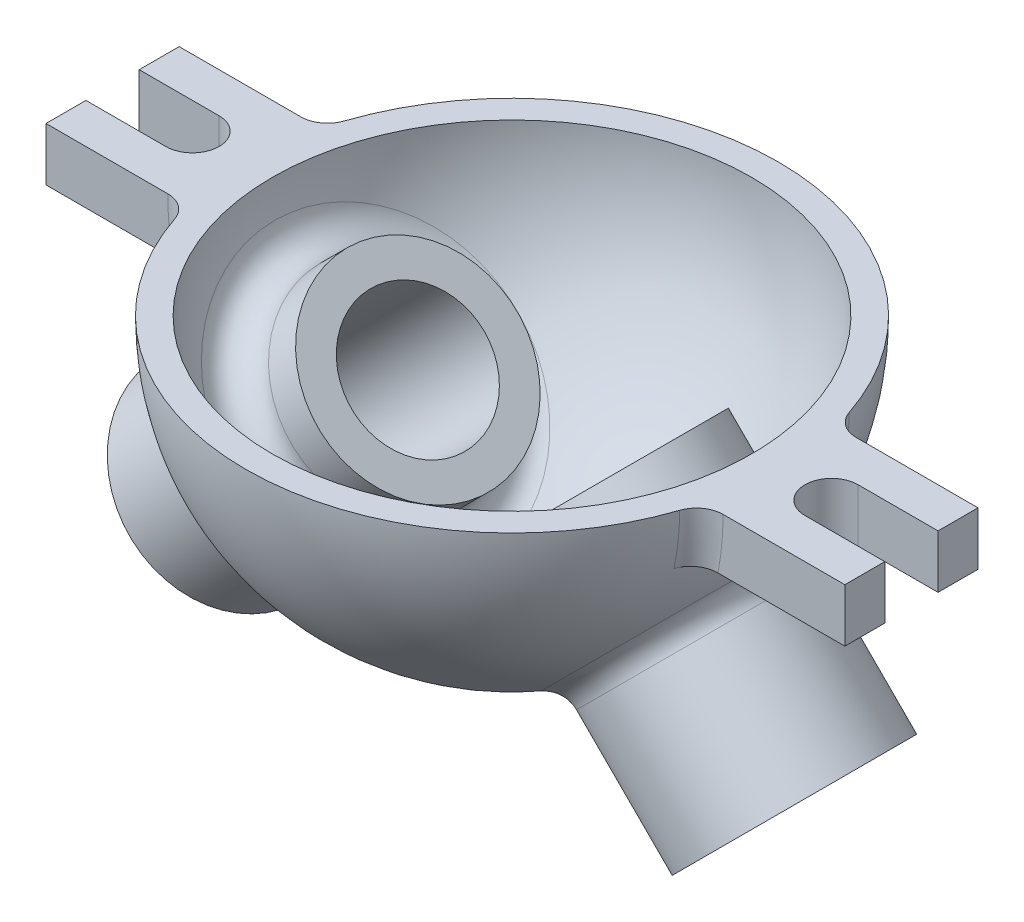
from build123d import *

# Parameters (mm, degrees)
REVOLVE_THIN1_ANGLE  = 180
BOSS_EXTRUDE1_START  = -55.263523
SKETCH4_W            = 50
SKETCH4_H            = 20
BOSS_EXTRUDE1_DEPTH  = 55.263523
CUT_EXTRUDE1_DEPTH   = 20
FILLET1_R            = 10
SKETCH6_R            = 37.5
SKETCH6_R_2          = 25
EXTRUDE_THIN1_DEPTH  = 100
SKETCH7_R            = 25
CUT_EXTRUDE2_DEPTH   = 100
FILLET2_R            = 10
FILLET2_OF_MIRROR2_R = 10


with BuildPart() as part:
    # Sketch1 → Revolve-Thin1 (revolve)
    with BuildSketch(Plane(origin=(0, 0, 0), x_dir=(1, 0, 0), z_dir=(0, 1, 0))):
        with BuildLine():
            ThreePointArc((0, 100), (100, 0), (0, -100))
            Line((0, -100), (0, -90))
            ThreePointArc((0, -90), (90, 0), (0, 90))
            Line((0, 90), (0, 100))
        make_face()
    revolve(axis=Axis((0, 0, 100), (0, 0, -1)), revolution_arc=REVOLVE_THIN1_ANGLE)

    # Sketch4 → Boss-Extrude1 (add)
    with BuildSketch(Plane(origin=(150, 0, 0), x_dir=(0, 0, -1), z_dir=(1, 0, 0)).offset(BOSS_EXTRUDE1_START)):
        with Locations((0, -10)):
            Rectangle(SKETCH4_W, SKETCH4_H)
    boss_extrude1 = extrude(amount=BOSS_EXTRUDE1_DEPTH)

    # Mirror1: Boss-Extrude1 across plane
    add(boss_extrude1.mirror(Plane(origin=(0, 0, 0), x_dir=(0, 0, 1), z_dir=(1, 0, 0))))

    # Sketch3 → Cut-Extrude1 (cut)
    with BuildSketch(Plane(origin=(0, 0, 0), x_dir=(1, 0, 0), z_dir=(0, 1, 0))):
        with BuildLine():
            Line((150, 10), (120, 10))
            ThreePointArc((120, 10), (110, 0), (120, -10))
            Line((120, -10), (150, -10))
            Line((150, -10), (150, 10))
        make_face()
        with BuildLine():
            Line((-120, -10), (-150, -10))
            Line((-150, -10), (-150, 10))
            Line((-150, 10), (-120, 10))
            ThreePointArc((-120, 10), (-110, 0), (-120, -10))
        make_face()
    extrude(amount=-CUT_EXTRUDE1_DEPTH, mode=Mode.SUBTRACT)

    # Fillet1
    fillet1_edges = [part.edges().sort_by_distance(p)[0] for p in [
        (96.301142013, -10.054354626, -25),
        (96.301142013, -10.054354626, 25),
        (-96.301142108, -10.054353722, 25),
        (-96.301142108, -10.054353722, -25),
    ]]
    fillet(fillet1_edges, radius=FILLET1_R)

    # Sketch6 → Extrude-Thin1 (add)
    with BuildSketch(Plane(origin=(106.066017178, -106.066017178, 0), x_dir=(0, 0, -1), z_dir=(0.707106781, -0.707106781, 0))):
        Circle(SKETCH6_R)
        Circle(SKETCH6_R_2, mode=Mode.SUBTRACT)
    extrude_thin1 = extrude(amount=-EXTRUDE_THIN1_DEPTH)

    # Sketch7 → Cut-Extrude2 (cut)
    with BuildSketch(Plane(origin=(106.066017178, -106.066017178, 0), x_dir=(0, 0, -1), z_dir=(0.707106781, -0.707106781, 0))):
        Circle(SKETCH7_R)
    cut_extrude2 = extrude(amount=-CUT_EXTRUDE2_DEPTH, mode=Mode.SUBTRACT)

    # Fillet2
    fillet2_edges = [part.edges().sort_by_distance(p)[0] for p in [
        (57.852182327, -57.852182327, 37.499999995),
        (65.55055301, -65.550553011, 37.499999995),
    ]]
    fillet(fillet2_edges, radius=FILLET2_R)

    # Mirror2: Extrude-Thin1, Cut-Extrude2 across plane
    add(extrude_thin1.mirror(Plane(origin=(0, 0, 0), x_dir=(0, 0, 1), z_dir=(1, 0, 0))))
    add(cut_extrude2.mirror(Plane(origin=(0, 0, 0), x_dir=(0, 0, 1), z_dir=(1, 0, 0))), mode=Mode.SUBTRACT)

    # Fillet2 of Mirror2
    fillet2_of_mirror2_edges = [part.edges().sort_by_distance(p)[0] for p in [
        (-57.852182327, -57.852182327, 37.499999995),
        (-65.55055301, -65.550553011, 37.499999995),
    ]]
    fillet(fillet2_of_mirror2_edges, radius=FILLET2_OF_MIRROR2_R)


solid = part.part
